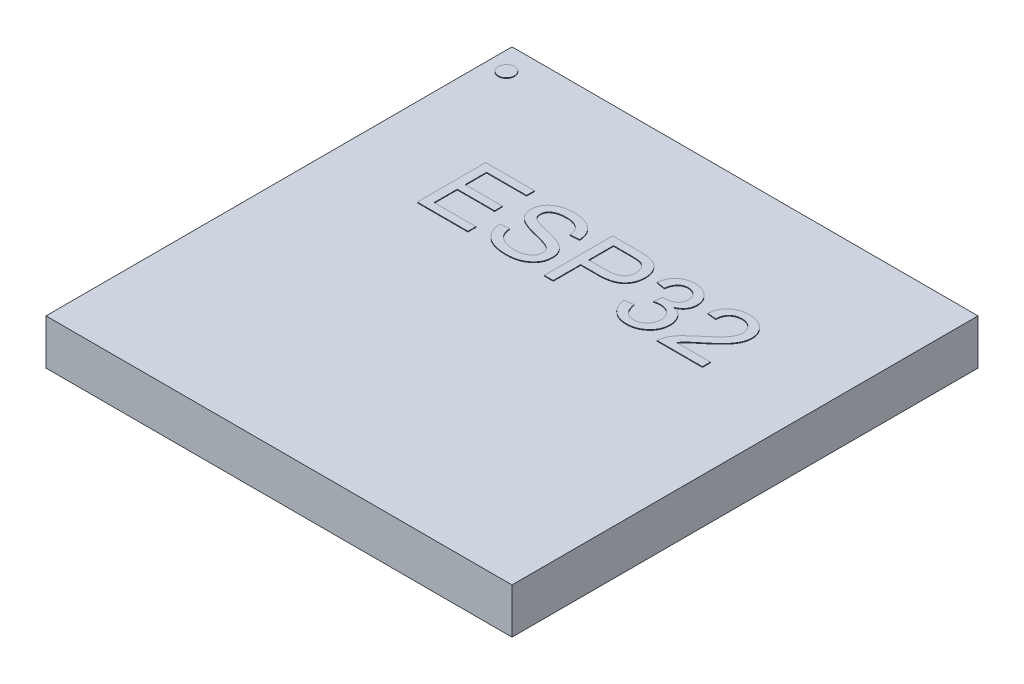
from build123d import *

# Parameters (mm, degrees)
ESQUISSE1_W        = 7
ESQUISSE1_H        = 7
BOSS_EXTRU_1_DEPTH = 0.68
BOSS_EXTRU_2_DEPTH = 0.01
ESQUISSE3_R        = 0.121165759
BOSS_EXTRU_3_DEPTH = 0.01


with BuildPart() as part:
    # Esquisse1 → Boss.-Extru.1 (new body)
    with BuildSketch(Plane(origin=(0, 0, 0), x_dir=(1, 0, 0), z_dir=(0, 1, 0))):
        with Locations((3.5, 3.5)):
            Rectangle(ESQUISSE1_W, ESQUISSE1_H)
    extrude(amount=BOSS_EXTRU_1_DEPTH)

    # Esquisse2 → Boss.-Extru.2 (add)
    with BuildSketch(Plane(origin=(0, 0.68, 0), x_dir=(1, 0, 0), z_dir=(0, 1, 0))):
        Polygon((2.078416989, 4.259616103), (1.31792782, 4.259616103), (1.31792782, 5.286943577), (2.051733159, 5.286943577), (2.051733159, 5.16686634), (1.451346972, 5.16686634), (1.451346972, 4.846660374), (2.011707413, 4.846660374), (2.011707413, 4.726583137), (1.451346972, 4.726583137), (1.451346972, 4.37969334), (2.078416989, 4.37969334), align=None)
        with BuildLine():
            add(Edge.make_bspline(
                [(2.892273819, 4.980079527), (2.891458143, 4.988163472), (2.889871608, 5.003887192), (2.884934389, 5.026534749), (2.878513488, 5.047688789), (2.870430456, 5.067360033), (2.860522972, 5.085426658), (2.849094521, 5.102074984), (2.835560862, 5.116902291), (2.820540709, 5.130352018), (2.803673422, 5.142049692), (2.785225234, 5.152278841), (2.765091758, 5.161113005), (2.743141524, 5.168137521), (2.719475659, 5.173471297), (2.694204199, 5.177459006), (2.667169755, 5.179707914), (2.648579484, 5.180037943), (2.638985897, 5.180208255)],
                knots=[0, 0, 0, 0, 1.074185969, 2.089350937, 3.060648602, 3.996266075, 4.897276924, 5.782244754, 6.661030791, 7.546666917, 8.444435611, 9.370427881, 10.33377434, 11.348439637, 12.414450767, 13.540496207, 14.730762825, 16, 16, 16, 16], degree=3))
            add(Edge.make_bspline(
                [(2.638985897, 5.180208255), (2.630295206, 5.180101584), (2.613309737, 5.179893101), (2.588486503, 5.177877406), (2.564843193, 5.175167429), (2.542537512, 5.170657527), (2.521339477, 5.165296363), (2.501375147, 5.158697405), (2.482691153, 5.150734531), (2.465465805, 5.141604773), (2.449705103, 5.131523141), (2.436090568, 5.119979856), (2.424480107, 5.107407744), (2.414997541, 5.093731621), (2.407567552, 5.078938508), (2.402407995, 5.062980071), (2.399168952, 5.045877292), (2.398808334, 5.034087616), (2.398622955, 5.028027034)],
                knots=[0, 0, 0, 0, 1.310601319, 2.56149684, 3.754995148, 4.897943153, 5.99111921, 7.051802007, 8.066155754, 9.050830736, 9.989872969, 10.882365417, 11.735521493, 12.564179929, 13.384509927, 14.223118814, 15.086579313, 16, 16, 16, 16], degree=3))
            add(Edge.make_bspline(
                [(2.398622955, 5.028027034), (2.398799679, 5.022739569), (2.399145535, 5.012391806), (2.401350394, 4.997378034), (2.405455949, 4.983435778), (2.410731392, 4.970423867), (2.417985877, 4.958652318), (2.426661466, 4.947860852), (2.436844658, 4.938055482), (2.448991582, 4.929313985), (2.463323083, 4.921050815), (2.480419083, 4.913120727), (2.500313895, 4.904851775), (2.523430364, 4.897186335), (2.549255913, 4.888735986), (2.578225303, 4.880691559), (2.610060258, 4.872567041), (2.63237239, 4.86745737), (2.643989115, 4.86479704)],
                knots=[0, 0, 0, 0, 0.788380427, 1.542889126, 2.254355691, 2.950807025, 3.629465713, 4.307333332, 5.010684187, 5.729652716, 6.532732684, 7.473358485, 8.537171846, 9.742749056, 11.102317802, 12.587863151, 14.223484221, 16, 16, 16, 16], degree=3))
            add(Edge.make_bspline(
                [(2.643989115, 4.86479704), (2.664515721, 4.860186896), (2.70374066, 4.851377226), (2.759340055, 4.836992686), (2.809082655, 4.822646457), (2.853676206, 4.808192768), (2.894023464, 4.791555543), (2.930603828, 4.770609031), (2.964381067, 4.745949953), (2.989894044, 4.722059222), (3.008038744, 4.700747073), (3.02005248, 4.683360015), (3.029986615, 4.664560292), (3.038238747, 4.644457782), (3.044625388, 4.623085827), (3.049225807, 4.600345099), (3.051967151, 4.576346199), (3.052238217, 4.559885982), (3.052376802, 4.551470499)],
                knots=[0, 0, 0, 0, 1.784517359, 3.410090522, 4.870782956, 6.175616015, 7.385395591, 8.565456745, 9.742097338, 10.926317608, 11.520302626, 12.113819479, 12.715072239, 13.320414222, 13.954464345, 14.604159014, 15.286359555, 16, 16, 16, 16], degree=3))
            add(Edge.make_bspline(
                [(3.052376802, 4.551470499), (3.052065806, 4.540749261), (3.051452435, 4.519603957), (3.046308066, 4.48861315), (3.037981604, 4.459007855), (3.026224863, 4.430861714), (3.011024644, 4.404188869), (2.992601074, 4.378845817), (2.970668815, 4.35499908), (2.945786411, 4.332617823), (2.918259508, 4.312279621), (2.888354179, 4.294706091), (2.85657107, 4.279631848), (2.822733006, 4.267299345), (2.786813346, 4.25803773), (2.749006595, 4.251062545), (2.709042148, 4.247185941), (2.681729592, 4.246582801), (2.667754402, 4.246274188)],
                knots=[0, 0, 0, 0, 0.937447744, 1.848911276, 2.739892169, 3.622768806, 4.51025874, 5.419794319, 6.357872599, 7.339307904, 8.343615577, 9.346579251, 10.369029688, 11.417128129, 12.492051004, 13.610511063, 14.777354915, 16, 16, 16, 16], degree=3))
            add(Edge.make_bspline(
                [(2.667754402, 4.246274188), (2.650093886, 4.246522409), (2.615821089, 4.247004119), (2.566143112, 4.251618968), (2.519937492, 4.259252317), (2.477175592, 4.26985131), (2.437739487, 4.283330274), (2.401668273, 4.299962861), (2.369114752, 4.319904142), (2.340001501, 4.342707307), (2.314416163, 4.368004018), (2.291902518, 4.395078222), (2.272544071, 4.423938269), (2.256787753, 4.454834524), (2.243625568, 4.487264367), (2.23418516, 4.521702595), (2.227512226, 4.557836729), (2.225964579, 4.582642319), (2.225178057, 4.595248659)],
                knots=[0, 0, 0, 0, 1.337067242, 2.594773381, 3.773871053, 4.880365675, 5.927089739, 6.925270948, 7.881893033, 8.811385527, 9.719298221, 10.601220961, 11.473959549, 12.344744758, 13.223191353, 14.11947094, 15.044304594, 16, 16, 16, 16], degree=3))
            Line((2.225178057, 4.595248659), (2.358597209, 4.6065059))
            add(Edge.make_bspline(
                [(2.358597209, 4.6065059), (2.359601314, 4.596405542), (2.361560412, 4.576698849), (2.367378431, 4.54831977), (2.375640275, 4.522048391), (2.386677789, 4.498078737), (2.399697586, 4.475990737), (2.415565327, 4.456292303), (2.433615765, 4.438553492), (2.454104854, 4.423273653), (2.476308409, 4.409997482), (2.499684231, 4.398363519), (2.524116042, 4.388176087), (2.549876318, 4.38041576), (2.576611472, 4.37413196), (2.604390243, 4.369541063), (2.633299909, 4.366761969), (2.652946927, 4.366490019), (2.662959651, 4.366351425)],
                knots=[0, 0, 0, 0, 1.122865222, 2.190809677, 3.200236324, 4.163943242, 5.10573287, 6.030631877, 6.955243028, 7.899729672, 8.852075219, 9.815168114, 10.787826015, 11.777963985, 12.789117926, 13.825950096, 14.892037327, 16, 16, 16, 16], degree=3))
            add(Edge.make_bspline(
                [(2.662959651, 4.366351425), (2.67227772, 4.366424112), (2.6905272, 4.36656647), (2.717161247, 4.369064821), (2.74249453, 4.372367553), (2.76632507, 4.377757375), (2.788891838, 4.38407012), (2.810073094, 4.392065502), (2.829917737, 4.401401697), (2.848230936, 4.412181589), (2.864738857, 4.424242607), (2.879217051, 4.437441014), (2.891689102, 4.45156339), (2.901553017, 4.467040958), (2.909290563, 4.483372989), (2.915045701, 4.500702656), (2.918429052, 4.519164216), (2.918779091, 4.531860536), (2.91895765, 4.538337051)],
                knots=[0, 0, 0, 0, 1.297723566, 2.541597437, 3.724634864, 4.854620901, 5.942509121, 6.987321542, 8.005091716, 8.994749768, 9.943642817, 10.848282642, 11.719938574, 12.560552629, 13.396413781, 14.232274933, 15.098266323, 16, 16, 16, 16], degree=3))
            add(Edge.make_bspline(
                [(2.91895765, 4.538337051), (2.91868677, 4.545018689), (2.918158461, 4.558050188), (2.914949591, 4.576922568), (2.908933039, 4.594277643), (2.900853363, 4.610364393), (2.889938903, 4.624749107), (2.877234362, 4.638155139), (2.861686694, 4.64956639), (2.843842455, 4.659839828), (2.823348775, 4.66943505), (2.799863558, 4.678682395), (2.77340874, 4.688302194), (2.743772732, 4.697845079), (2.710984836, 4.707329683), (2.675124571, 4.717269133), (2.635978111, 4.726659322), (2.594750499, 4.73613676), (2.553455214, 4.745895861), (2.514243034, 4.756849081), (2.478101414, 4.768989126), (2.44493567, 4.781814937), (2.414816956, 4.79552079), (2.387799004, 4.810159613), (2.363642955, 4.825463333), (2.342617682, 4.842092747), (2.324242827, 4.859697219), (2.308521412, 4.878628154), (2.295033117, 4.898681134), (2.284190485, 4.920150324), (2.275500521, 4.94281754), (2.269553323, 4.966834508), (2.265934663, 4.992060503), (2.265450648, 5.00925267), (2.265203802, 5.018020598)],
                knots=[0, 0, 0, 0, 0.723868206, 1.411792909, 2.063877326, 2.706733565, 3.352446663, 4.012387282, 4.700229653, 5.43207343, 6.239981892, 7.148338879, 8.164853486, 9.288162601, 10.519353264, 11.861213999, 13.317764598, 14.878544114, 16.44280323, 17.912764986, 19.285915536, 20.570239708, 21.762330489, 22.866853123, 23.895992285, 24.855057353, 25.765158427, 26.646811786, 27.515098876, 28.37670724, 29.246069892, 30.138608469, 31.050698702, 32, 32, 32, 32], degree=3))
            add(Edge.make_bspline(
                [(2.265203802, 5.018020598), (2.265432395, 5.028049062), (2.26588125, 5.047740604), (2.270962278, 5.076523698), (2.278613152, 5.103940584), (2.289279716, 5.130143844), (2.303464989, 5.154765811), (2.320369037, 5.178303072), (2.340648582, 5.200262701), (2.363717633, 5.220841938), (2.389472088, 5.239516707), (2.417602548, 5.255886178), (2.447998906, 5.269659647), (2.480612286, 5.280866403), (2.515411884, 5.289635289), (2.552431419, 5.295799821), (2.591722433, 5.299617379), (2.618686061, 5.300058907), (2.632523407, 5.300285492)],
                knots=[0, 0, 0, 0, 0.926550128, 1.819341648, 2.694187658, 3.555880559, 4.427960269, 5.316276151, 6.230620717, 7.186506714, 8.171211291, 9.167674199, 10.191552338, 11.252497888, 12.352962012, 13.506726908, 14.720488204, 16, 16, 16, 16], degree=3))
            add(Edge.make_bspline(
                [(2.632523407, 5.300285492), (2.646708501, 5.300059587), (2.674435425, 5.299618022), (2.714963524, 5.295757248), (2.753411793, 5.289709047), (2.789587626, 5.280575743), (2.823810494, 5.269495086), (2.855724099, 5.255356678), (2.885781174, 5.239217385), (2.913289801, 5.220148305), (2.938291979, 5.198993646), (2.960490841, 5.175703169), (2.979310362, 5.150092392), (2.995114547, 5.122341404), (3.00756675, 5.092409912), (3.016992892, 5.060408669), (3.023320947, 5.026306424), (3.024890104, 5.002759351), (3.025692971, 4.990711365)],
                knots=[0, 0, 0, 0, 1.212885338, 2.37076898, 3.478710175, 4.538122684, 5.558597714, 6.551229896, 7.519273668, 8.472093132, 9.408064746, 10.316111179, 11.217090085, 12.119342099, 13.040958781, 13.983042329, 14.968012869, 16, 16, 16, 16], degree=3))
            Line((3.025692971, 4.990711365), (2.892273819, 4.980079527))
        make_face()
        with BuildLine():
            Line((3.2258217, 5.286943577), (3.615238851, 5.286943577))
            add(Edge.make_bspline(
                [(3.615238851, 5.286943577), (3.630041067, 5.286808789), (3.658612949, 5.286548615), (3.699921502, 5.284981159), (3.738009413, 5.281970799), (3.773392738, 5.278345332), (3.806664547, 5.271974308), (3.838440768, 5.2618663), (3.868924697, 5.248048006), (3.897933439, 5.230725972), (3.924928827, 5.210122379), (3.948417622, 5.18542367), (3.968493892, 5.157390836), (3.984422648, 5.1261767), (3.997056588, 5.093141016), (4.006318555, 5.059007653), (4.011864016, 5.024039167), (4.012616898, 5.00045926), (4.0129947, 4.988626691)],
                knots=[0, 0, 0, 0, 1.244157682, 2.401527469, 3.473468824, 4.455130815, 5.389799171, 6.315206347, 7.251005401, 8.196559236, 9.149855764, 10.095824383, 11.0504261, 12.037874139, 13.032515979, 14.018598527, 15.005718329, 16, 16, 16, 16], degree=3))
            add(Edge.make_bspline(
                [(4.0129947, 4.988626691), (4.012732816, 4.977006225), (4.012219651, 4.954235673), (4.007664363, 4.921039312), (4.000747754, 4.889467281), (3.990415984, 4.859824038), (3.97744768, 4.831831813), (3.96155797, 4.805636072), (3.942575012, 4.781323412), (3.92090062, 4.758676243), (3.895910384, 4.738223255), (3.867300246, 4.72074914), (3.835335132, 4.705888565), (3.799880016, 4.693875687), (3.760934425, 4.684545283), (3.718531316, 4.678102872), (3.672727591, 4.673740825), (3.641030347, 4.673394683), (3.624619886, 4.673215476)],
                knots=[0, 0, 0, 0, 0.978177196, 1.916759246, 2.816858773, 3.695957288, 4.554717961, 5.410842432, 6.270061616, 7.147502833, 8.04596474, 8.981440044, 9.963234339, 11.008881904, 12.128796686, 13.33146493, 14.618432235, 16, 16, 16, 16], degree=3))
            Line((3.624619886, 4.673215476), (3.359240853, 4.673215476))
            Line((3.359240853, 4.673215476), (3.359240853, 4.259616103))
            Line((3.359240853, 4.259616103), (3.2258217, 4.259616103))
            Line((3.2258217, 4.259616103), (3.2258217, 5.286943577))
        make_face()
        with BuildLine():
            Line((3.359240853, 4.793292713), (3.630665441, 4.793292713))
            add(Edge.make_bspline(
                [(3.630665441, 4.793292713), (3.640743962, 4.793482582), (3.660228065, 4.793849644), (3.68851329, 4.795819225), (3.714758364, 4.799590268), (3.739196491, 4.804709546), (3.761586922, 4.811646682), (3.782274318, 4.819582632), (3.800659003, 4.829651231), (3.817569698, 4.840431195), (3.832019941, 4.853496689), (3.844881207, 4.867600539), (3.855632428, 4.883491418), (3.86430323, 4.900845363), (3.871356975, 4.919601776), (3.875984757, 4.939941968), (3.8789838, 4.961714927), (3.879374576, 4.976733466), (3.879575547, 4.984457342)],
                knots=[0, 0, 0, 0, 1.3506626, 2.611141784, 3.796285978, 4.901204962, 5.9527306, 6.934848657, 7.863795126, 8.757347314, 9.614903967, 10.465506862, 11.310023167, 12.176181001, 13.060025945, 13.98827215, 14.965389641, 16, 16, 16, 16], degree=3))
            add(Edge.make_bspline(
                [(3.879575547, 4.984457342), (3.879175622, 4.994632883), (3.878393005, 5.014545466), (3.872225321, 5.043476338), (3.861860305, 5.070506144), (3.847771665, 5.095227502), (3.831073094, 5.11705421), (3.811768072, 5.134429875), (3.79079628, 5.147700726), (3.766844334, 5.155855383), (3.739433604, 5.160759387), (3.707264762, 5.164487186), (3.6693918, 5.166338296), (3.642271534, 5.166682172), (3.627746897, 5.16686634)],
                knots=[0, 0, 0, 0, 1.018660659, 1.99342392, 2.947462538, 3.907551051, 4.834908788, 5.687573627, 6.497006468, 7.302839678, 8.203828931, 9.283092672, 10.544922364, 12, 12, 12, 12], degree=3))
            Line((3.627746897, 5.16686634), (3.359240853, 5.16686634))
            Line((3.359240853, 5.16686634), (3.359240853, 4.793292713))
        make_face(mode=Mode.SUBTRACT)
        with BuildLine():
            add(Edge.make_bspline(
                [(4.618801039, 4.814764858), (4.626616545, 4.813090756), (4.641934151, 4.809809683), (4.663970065, 4.802716434), (4.684386276, 4.793635976), (4.703566015, 4.783339411), (4.721013072, 4.770805835), (4.737016351, 4.756703302), (4.751591649, 4.740823223), (4.764590202, 4.723463853), (4.775846779, 4.704943027), (4.786024522, 4.686080547), (4.794535051, 4.666774138), (4.801467774, 4.6469714), (4.806908757, 4.626844796), (4.810633277, 4.606197592), (4.81298568, 4.585227092), (4.813334695, 4.57107254), (4.813509614, 4.563978545)],
                knots=[0, 0, 0, 0, 1.108697074, 2.172934788, 3.204880389, 4.206093888, 5.188037506, 6.178607442, 7.161308294, 8.17378834, 9.182634384, 10.166186428, 11.146234401, 12.106878305, 13.075234477, 14.036023556, 15.015691959, 16, 16, 16, 16], degree=3))
            add(Edge.make_bspline(
                [(4.813509614, 4.563978545), (4.813161528, 4.552637711), (4.812477411, 4.530348851), (4.807911789, 4.497682867), (4.799964766, 4.466648536), (4.788756931, 4.437191087), (4.774646463, 4.409095355), (4.756932366, 4.382814169), (4.736342649, 4.357935049), (4.712718555, 4.335116196), (4.687001946, 4.314378536), (4.659799591, 4.296160611), (4.631384313, 4.280604866), (4.601587037, 4.268114561), (4.570638582, 4.258199174), (4.538358446, 4.251429467), (4.504885685, 4.247120274), (4.482129279, 4.246559018), (4.470580699, 4.246274188)],
                knots=[0, 0, 0, 0, 1.04348772, 2.050832607, 3.027849651, 3.985018456, 4.945832333, 5.91410632, 6.89488226, 7.912262782, 8.930828092, 9.931024771, 10.921011636, 11.90669419, 12.899588269, 13.906628715, 14.937641313, 16, 16, 16, 16], degree=3))
            add(Edge.make_bspline(
                [(4.470580699, 4.246274188), (4.459588516, 4.246496438), (4.43802439, 4.246932441), (4.406467743, 4.25088713), (4.376308432, 4.256676294), (4.347798069, 4.265692259), (4.32050691, 4.27659075), (4.294881346, 4.290454115), (4.270685369, 4.306673941), (4.248040021, 4.325073306), (4.227453357, 4.345811938), (4.208822854, 4.368039713), (4.192640759, 4.392120315), (4.178703407, 4.417643133), (4.167152046, 4.444906941), (4.157830606, 4.47364207), (4.150608486, 4.504035708), (4.147829714, 4.524963622), (4.146413852, 4.535626975)],
                knots=[0, 0, 0, 0, 1.097840809, 2.15371029, 3.173627445, 4.161928108, 5.136697, 6.10591076, 7.066857035, 8.04392302, 9.016042305, 9.982391694, 10.93757629, 11.910092237, 12.8837972, 13.891636589, 14.925730372, 16, 16, 16, 16], degree=3))
            Line((4.146413852, 4.535626975), (4.279833005, 4.553138239))
            add(Edge.make_bspline(
                [(4.279833005, 4.553138239), (4.281397353, 4.544984747), (4.284439025, 4.52913135), (4.290581549, 4.506408877), (4.297398482, 4.485198984), (4.305333208, 4.465548881), (4.314194777, 4.447463529), (4.324110336, 4.431059225), (4.334747705, 4.416131134), (4.346395112, 4.4027002), (4.359237232, 4.391035458), (4.372804855, 4.380666954), (4.387510386, 4.372067401), (4.403233431, 4.365241373), (4.419836634, 4.359772483), (4.437415211, 4.355787023), (4.455998542, 4.353527647), (4.468698545, 4.353184357), (4.475166983, 4.35300951)],
                knots=[0, 0, 0, 0, 1.291404279, 2.510966685, 3.659843074, 4.756126606, 5.80544111, 6.790091746, 7.735305102, 8.654813164, 9.550164339, 10.430304926, 11.307451716, 12.193417606, 13.092677492, 14.023872142, 14.99350733, 16, 16, 16, 16], degree=3))
            add(Edge.make_bspline(
                [(4.475166983, 4.35300951), (4.482191778, 4.353243946), (4.496015153, 4.353705267), (4.516383631, 4.356333523), (4.535794733, 4.36128725), (4.554565342, 4.367609745), (4.57227778, 4.376413564), (4.589541072, 4.386456041), (4.605529282, 4.3989832), (4.620738549, 4.412848155), (4.634567348, 4.428129682), (4.64676182, 4.444439914), (4.656977861, 4.461682065), (4.665659437, 4.479595395), (4.672149244, 4.498582306), (4.676582123, 4.518377558), (4.679752497, 4.538931034), (4.679976661, 4.552917294), (4.680090462, 4.560017664)],
                knots=[0, 0, 0, 0, 1.039414619, 2.045357549, 3.030071188, 3.998775674, 4.968788042, 5.950654362, 6.947736046, 7.966204168, 8.99226847, 9.991361361, 10.97322768, 11.952508152, 12.930925156, 13.933238126, 14.950772207, 16, 16, 16, 16], degree=3))
            add(Edge.make_bspline(
                [(4.680090462, 4.560017664), (4.679961328, 4.566838733), (4.67970856, 4.580190355), (4.676800045, 4.599779571), (4.672580576, 4.618546981), (4.666257297, 4.636345515), (4.658191443, 4.653186023), (4.648691551, 4.669315518), (4.637057143, 4.684416249), (4.623783387, 4.698438743), (4.609263086, 4.711351546), (4.593576201, 4.722776923), (4.576599104, 4.732043445), (4.558707881, 4.739914229), (4.539680377, 4.745887432), (4.519603588, 4.750314721), (4.498439209, 4.752798128), (4.483998362, 4.753108514), (4.476626255, 4.753266967)],
                knots=[0, 0, 0, 0, 1.039520793, 2.03476737, 3.014257368, 3.969595977, 4.908269218, 5.858892987, 6.819157264, 7.808857987, 8.799919747, 9.779409745, 10.761476676, 11.744001019, 12.756257763, 13.797775717, 14.875756186, 16, 16, 16, 16], degree=3))
            add(Edge.make_bspline(
                [(4.476626255, 4.753266967), (4.470156876, 4.753088679), (4.456480686, 4.752711778), (4.434975268, 4.749999614), (4.411383218, 4.745848663), (4.395096646, 4.741960864), (4.386568327, 4.739925052)],
                knots=[0, 0, 0, 0, 0.850710824, 1.798392532, 2.847147604, 4, 4, 4, 4], degree=3))
            Line((4.386568327, 4.739925052), (4.400952579, 4.860002289))
            add(Edge.make_bspline(
                [(4.400952579, 4.860002289), (4.408807487, 4.859983327), (4.423622051, 4.859947563), (4.444527923, 4.861231524), (4.462849089, 4.862211451), (4.479249512, 4.864324221), (4.494709949, 4.867821546), (4.510578063, 4.872643809), (4.52715485, 4.87944864), (4.544471737, 4.887518156), (4.561437046, 4.897590855), (4.577261072, 4.909699733), (4.59121492, 4.924105333), (4.603898157, 4.940083411), (4.614253182, 4.958352044), (4.621478196, 4.978811144), (4.625990745, 5.001285876), (4.626472264, 5.016955485), (4.626722801, 5.025108491)],
                knots=[0, 0, 0, 0, 1.189476569, 2.243384405, 3.171816706, 3.968247766, 4.74460194, 5.57033408, 6.477275893, 7.456583362, 8.462071333, 9.460038224, 10.464864835, 11.49237022, 12.543383061, 13.628830431, 14.766264109, 16, 16, 16, 16], degree=3))
            add(Edge.make_bspline(
                [(4.626722801, 5.025108491), (4.626530576, 5.031088767), (4.626156123, 5.042738262), (4.624176818, 5.059742745), (4.620344771, 5.07564275), (4.615230762, 5.090624139), (4.608136803, 5.104380757), (4.600168387, 5.117478505), (4.590178493, 5.129187502), (4.575273976, 5.143148519), (4.554637156, 5.157953251), (4.527432758, 5.1707365), (4.498291187, 5.178927577), (4.478140336, 5.179775909), (4.467870623, 5.180208255)],
                knots=[0, 0, 0, 0, 0.865373357, 1.68573535, 2.470791522, 3.227405046, 3.969116108, 4.705358259, 5.440226823, 6.186825656, 7.656768999, 9.091088923, 10.517497636, 12, 12, 12, 12], degree=3))
            add(Edge.make_bspline(
                [(4.467870623, 5.180208255), (4.462026645, 5.180034788), (4.450502113, 5.179692705), (4.433668293, 5.177396343), (4.417633026, 5.173573062), (4.402370347, 5.168503196), (4.38808233, 5.161407393), (4.374506842, 5.153173155), (4.361838901, 5.143167442), (4.350065667, 5.131763525), (4.339152138, 5.119051107), (4.329532629, 5.104843966), (4.32077845, 5.089455871), (4.313096795, 5.072700686), (4.30635161, 5.054757762), (4.301096052, 5.035445907), (4.296357267, 5.014958965), (4.294255782, 5.000736515), (4.29317492, 4.993421442)],
                knots=[0, 0, 0, 0, 0.991350633, 1.954978605, 2.875684831, 3.785306039, 4.676327725, 5.576040997, 6.474517762, 7.408263042, 8.35317801, 9.311237712, 10.314294325, 11.353349771, 12.435063167, 13.562077035, 14.746096111, 16, 16, 16, 16], degree=3))
            Line((4.29317492, 4.993421442), (4.159755767, 5.016769793))
            add(Edge.make_bspline(
                [(4.159755767, 5.016769793), (4.161862241, 5.027724739), (4.165992328, 5.049203713), (4.175188193, 5.079879128), (4.185330774, 5.108727814), (4.198127153, 5.13505693), (4.212067583, 5.159678262), (4.22856447, 5.181691569), (4.246282086, 5.202068017), (4.266197149, 5.219870268), (4.287356883, 5.235688878), (4.309698014, 5.249269069), (4.332851935, 5.261175548), (4.357299641, 5.270288861), (4.382491666, 5.278094356), (4.408852074, 5.283125822), (4.436171335, 5.286368857), (4.45472759, 5.286750462), (4.464118209, 5.286943577)],
                knots=[0, 0, 0, 0, 1.196598026, 2.346127519, 3.433890862, 4.474795076, 5.484142389, 6.465743017, 7.422110934, 8.377896977, 9.32664338, 10.254070249, 11.18137714, 12.11636131, 13.050809827, 14.008921245, 14.99239035, 16, 16, 16, 16], degree=3))
            add(Edge.make_bspline(
                [(4.464118209, 5.286943577), (4.474481546, 5.286693862), (4.494783823, 5.286204659), (4.524589398, 5.282640832), (4.553024002, 5.276537013), (4.580249594, 5.268308559), (4.606008922, 5.257306834), (4.630590654, 5.244180207), (4.653739048, 5.228397849), (4.675568377, 5.210668848), (4.695109283, 5.190918985), (4.712694432, 5.170271659), (4.727331415, 5.14827442), (4.739257099, 5.125170187), (4.748798485, 5.10104285), (4.755368997, 5.075770299), (4.759513936, 5.049428151), (4.759930082, 5.031517304), (4.760141953, 5.022398414)],
                knots=[0, 0, 0, 0, 1.123761111, 2.201502124, 3.249427722, 4.274422765, 5.280770574, 6.282168429, 7.291699599, 8.314503797, 9.32695594, 10.300518959, 11.251508239, 12.185140702, 13.11575736, 14.058951515, 15.011760414, 16, 16, 16, 16], degree=3))
            add(Edge.make_bspline(
                [(4.760141953, 5.022398414), (4.759687496, 5.010904245), (4.758804023, 4.988559358), (4.752359143, 4.956282413), (4.741093729, 4.926643949), (4.725562674, 4.899353698), (4.705199709, 4.87484249), (4.680669924, 4.85269483), (4.651639819, 4.833174771), (4.629998964, 4.822828531), (4.618801039, 4.817474934)],
                knots=[0, 0, 0, 0, 1.039587536, 2.020978204, 2.96205572, 3.896981787, 4.848417189, 5.832040328, 6.87820286, 8, 8, 8, 8], degree=3))
            Line((4.618801039, 4.817474934), (4.618801039, 4.814764858))
        make_face()
        with BuildLine():
            Line((5.600682614, 4.259616103), (4.920244936, 4.259616103))
            add(Edge.make_bspline(
                [(4.920244936, 4.259616103), (4.920487126, 4.266779825), (4.920975469, 4.281224536), (4.923655454, 4.302951636), (4.928593641, 4.3247361), (4.935193517, 4.346582703), (4.943917462, 4.368400572), (4.954261973, 4.390363955), (4.966994427, 4.412173374), (4.981202642, 4.434665588), (4.998450406, 4.457636516), (5.018772892, 4.481716353), (5.042091313, 4.507494141), (5.069225904, 4.534180778), (5.099118671, 4.562904526), (5.132754253, 4.592512366), (5.169560308, 4.623670831), (5.195382782, 4.64463317), (5.208763854, 4.655495745)],
                knots=[0, 0, 0, 0, 0.679636028, 1.370397483, 2.072386496, 2.795828244, 3.532596575, 4.299069294, 5.096101743, 5.926104732, 6.821123359, 7.817706802, 8.914074387, 10.116429551, 11.426377678, 12.845587515, 14.365399908, 16, 16, 16, 16], degree=3))
            add(Edge.make_bspline(
                [(5.208763854, 4.655495745), (5.225334632, 4.669063671), (5.258087716, 4.695881447), (5.304777574, 4.737662086), (5.34820427, 4.780688225), (5.382379747, 4.816926569), (5.407154687, 4.846528172), (5.423419762, 4.868554731), (5.436632157, 4.890982966), (5.447970494, 4.913144209), (5.456437777, 4.935557461), (5.462885029, 4.95789241), (5.466460464, 4.980380951), (5.46699677, 4.995355825), (5.467263462, 5.002802476)],
                knots=[0, 0, 0, 0, 1.727365886, 3.414236585, 5.051125997, 6.657366303, 7.42955054, 8.163886393, 8.862711004, 9.526964272, 10.169215867, 10.792073404, 11.3993267, 12, 12, 12, 12], degree=3))
            add(Edge.make_bspline(
                [(5.467263462, 5.002802476), (5.467107396, 5.009065282), (5.46679919, 5.021433423), (5.464242036, 5.039517645), (5.460150696, 5.056830321), (5.453954369, 5.07309044), (5.446464061, 5.088763971), (5.437049965, 5.103440238), (5.426116391, 5.11742912), (5.413440785, 5.130192076), (5.399530791, 5.141820373), (5.384662172, 5.152070007), (5.368960709, 5.160951743), (5.352228376, 5.168021228), (5.334600557, 5.173400439), (5.316206095, 5.17741668), (5.296863953, 5.179699432), (5.283679001, 5.180036029), (5.276932702, 5.180208255)],
                knots=[0, 0, 0, 0, 1.031756814, 2.037571546, 3.00421938, 3.957270543, 4.899734611, 5.862439424, 6.824735417, 7.820853428, 8.820913875, 9.808900714, 10.793363174, 11.788888474, 12.795941292, 13.826998675, 14.888147937, 16, 16, 16, 16], degree=3))
            add(Edge.make_bspline(
                [(5.276932702, 5.180208255), (5.270116755, 5.180037128), (5.256792945, 5.179702608), (5.237178912, 5.177395399), (5.218435165, 5.173402291), (5.200394142, 5.168020775), (5.183243185, 5.16096112), (5.167088486, 5.152025336), (5.151654756, 5.141816231), (5.136985082, 5.1302594), (5.123854533, 5.116860605), (5.112253323, 5.101926026), (5.102440125, 5.085406772), (5.094488905, 5.067249175), (5.0882949, 5.047597079), (5.083684877, 5.026465943), (5.081000856, 5.003773952), (5.080570242, 4.988147403), (5.080347919, 4.980079527)],
                knots=[0, 0, 0, 0, 1.031812441, 2.01698662, 2.984649478, 3.929806142, 4.863654442, 5.786355652, 6.720026173, 7.663072848, 8.607819605, 9.552624931, 10.519658563, 11.508756638, 12.546771345, 13.634199285, 14.778553981, 16, 16, 16, 16], degree=3))
            Line((5.080347919, 4.980079527), (4.946928767, 4.994463779))
            add(Edge.make_bspline(
                [(4.946928767, 4.994463779), (4.948124452, 5.005956959), (4.950465755, 5.028462075), (4.957169325, 5.060982214), (4.966360428, 5.091487316), (4.978019066, 5.11983345), (4.991996969, 5.146237583), (5.008834104, 5.17022561), (5.027871917, 5.192344063), (5.049476556, 5.212102924), (5.072927916, 5.229778955), (5.098115796, 5.245048923), (5.124707873, 5.258003795), (5.152783637, 5.268754462), (5.182495197, 5.276782622), (5.213654119, 5.282594736), (5.246341893, 5.286222763), (5.268653958, 5.286699747), (5.280059713, 5.286943577)],
                knots=[0, 0, 0, 0, 1.12136465, 2.195775393, 3.218105421, 4.210407851, 5.16726023, 6.11240982, 7.049846341, 7.995212629, 8.94920645, 9.896857076, 10.850349768, 11.817681837, 12.811199131, 13.834063315, 14.892789946, 16, 16, 16, 16], degree=3))
            add(Edge.make_bspline(
                [(5.280059713, 5.286943577), (5.292371809, 5.286741275), (5.31629956, 5.286348113), (5.351144889, 5.282209437), (5.383971041, 5.2759019), (5.414736973, 5.266771165), (5.443284344, 5.25480684), (5.469729245, 5.240297841), (5.494308814, 5.223478412), (5.516320837, 5.203766717), (5.535886359, 5.182346386), (5.553541686, 5.160091749), (5.567789464, 5.136225361), (5.580198208, 5.111651738), (5.589178917, 5.085643848), (5.595996948, 5.058751903), (5.600024545, 5.030720447), (5.600461248, 5.011640355), (5.600682614, 5.001968606)],
                knots=[0, 0, 0, 0, 1.226590804, 2.383798815, 3.492161376, 4.554899855, 5.576207927, 6.571155829, 7.556730587, 8.537964122, 9.50843264, 10.446325096, 11.36332231, 12.273967998, 13.185245566, 14.099046289, 15.036401571, 16, 16, 16, 16], degree=3))
            add(Edge.make_bspline(
                [(5.600682614, 5.001968606), (5.600492573, 4.993757996), (5.60010933, 4.977200175), (5.596625444, 4.952360281), (5.59096838, 4.927397586), (5.582964106, 4.902412515), (5.572950813, 4.877292977), (5.5605889, 4.852215357), (5.545826197, 4.827207158), (5.528972582, 4.801473694), (5.508435472, 4.774841479), (5.484084163, 4.74625364), (5.454840639, 4.71600816), (5.421671346, 4.683136479), (5.38390905, 4.648256048), (5.341748756, 4.611102538), (5.29506225, 4.572041459), (5.262244122, 4.545580351), (5.245245653, 4.531874561)],
                knots=[0, 0, 0, 0, 0.647272069, 1.305312805, 1.974061086, 2.663900091, 3.372213675, 4.105057161, 4.866424047, 5.66138998, 6.529516392, 7.516877935, 8.621658815, 9.846264054, 11.199666148, 12.675197319, 14.277886024, 16, 16, 16, 16], degree=3))
            add(Edge.make_bspline(
                [(5.245245653, 4.531874561), (5.236233108, 4.524636595), (5.21884561, 4.510672713), (5.194417052, 4.489478716), (5.172088912, 4.469270566), (5.151841008, 4.450029712), (5.133990193, 4.431357133), (5.118466462, 4.4135088), (5.104827167, 4.396654543), (5.097288681, 4.385174074), (5.093689835, 4.37969334)],
                knots=[0, 0, 0, 0, 1.28638092, 2.481756772, 3.598704207, 4.637980996, 5.589780294, 6.472288135, 7.270675925, 8, 8, 8, 8], degree=3))
            Line((5.093689835, 4.37969334), (5.600682614, 4.37969334))
            Line((5.600682614, 4.37969334), (5.600682614, 4.259616103))
        make_face()
    extrude(amount=BOSS_EXTRU_2_DEPTH)

    # Esquisse3 → Boss.-Extru.3 (add)
    with BuildSketch(Plane(origin=(0, 0.68, 0), x_dir=(1, 0, 0), z_dir=(0, 1, 0))):
        with Locations(Location((0.28444717, 6.631499435, 0), (0, 0, 90))):
            Circle(ESQUISSE3_R)
    extrude(amount=BOSS_EXTRU_3_DEPTH)


solid = part.part
